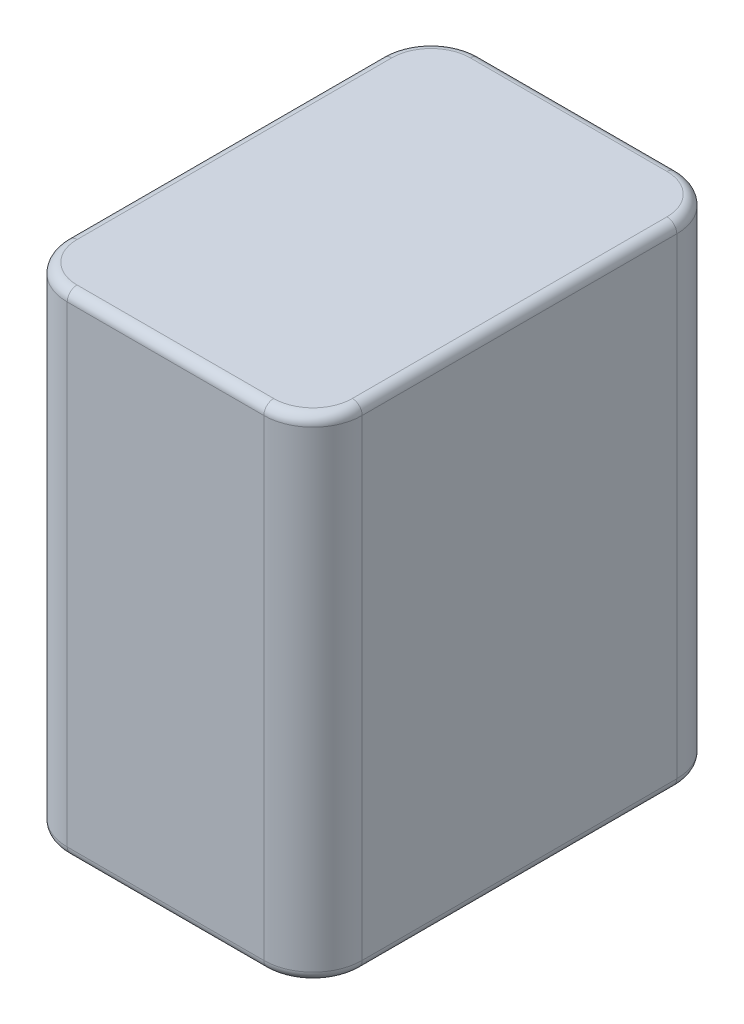
from build123d import *

# Parameters (mm, degrees)
SKETCH1_W           = 30
SKETCH1_H           = 42
BOSS_EXTRUDE1_DEPTH = 25
FILLET1_R           = 5
FILLET2_R           = 1
FILLET3_R           = 1


with BuildPart() as part:
    # Sketch1 → Boss-Extrude1 (new body, symmetric)
    with BuildSketch(Plane(origin=(0, 0, 0), x_dir=(1, 0, 0), z_dir=(0, 1, 0))):
        with Locations((15, 21)):
            Rectangle(SKETCH1_W, SKETCH1_H)
    extrude(amount=BOSS_EXTRUDE1_DEPTH, both=True)

    # Fillet1
    fillet1_edges = [part.edges().sort_by_distance(p)[0] for p in [
        (0, 0, -42),
        (30, 0, -42),
        (30, 0, 0),
        (0, 0, 0),
    ]]
    fillet(fillet1_edges, radius=FILLET1_R)

    # Fillet2
    fillet2_edges = [part.edges().sort_by_distance(p)[0] for p in [
        (0, 25, -21),
        (15, 25, -42),
        (15, 25, 0),
        (30, 25, -21),
        (28.535533906, 25, -1.464466094),
        (28.535533906, 25, -40.535533906),
        (1.464466094, 25, -1.464466094),
        (1.464466094, 25, -40.535533906),
    ]]
    fillet(fillet2_edges, radius=FILLET2_R)

    # Fillet3
    fillet3_edges = [part.edges().sort_by_distance(p)[0] for p in [
        (0, -25, -21),
        (15, -25, -42),
        (30, -25, -21),
        (15, -25, 0),
        (28.535533906, -25, -1.464466094),
        (28.535533906, -25, -40.535533906),
        (1.464466094, -25, -1.464466094),
        (1.464466094, -25, -40.535533906),
    ]]
    fillet(fillet3_edges, radius=FILLET3_R)


solid = part.part
